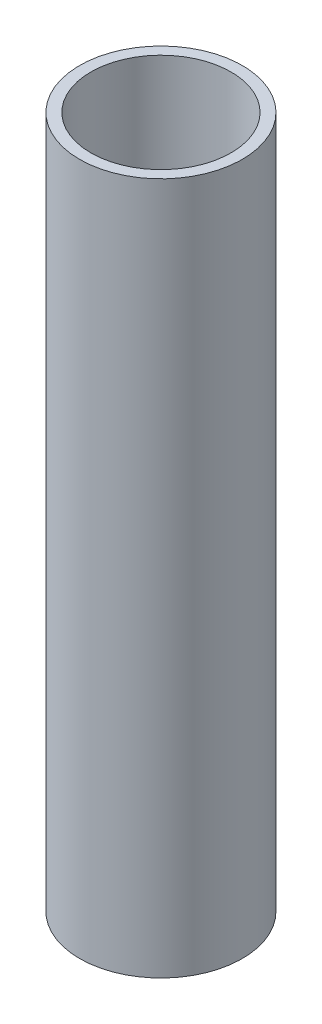
from build123d import *

# Parameters (mm, degrees)
SKETCH2_R           = 30.1625
SKETCH2_R_2         = 25.9969
BOSS_EXTRUDE1_DEPTH = 256.625


with BuildPart() as part:
    # Sketch2 → Boss-Extrude1 (new body)
    with BuildSketch(Plane(origin=(0, 0, 0), x_dir=(1, 0, 0), z_dir=(0, 1, 0))):
        Circle(SKETCH2_R)
        Circle(SKETCH2_R_2, mode=Mode.SUBTRACT)
    extrude(amount=BOSS_EXTRUDE1_DEPTH)


solid = part.part
